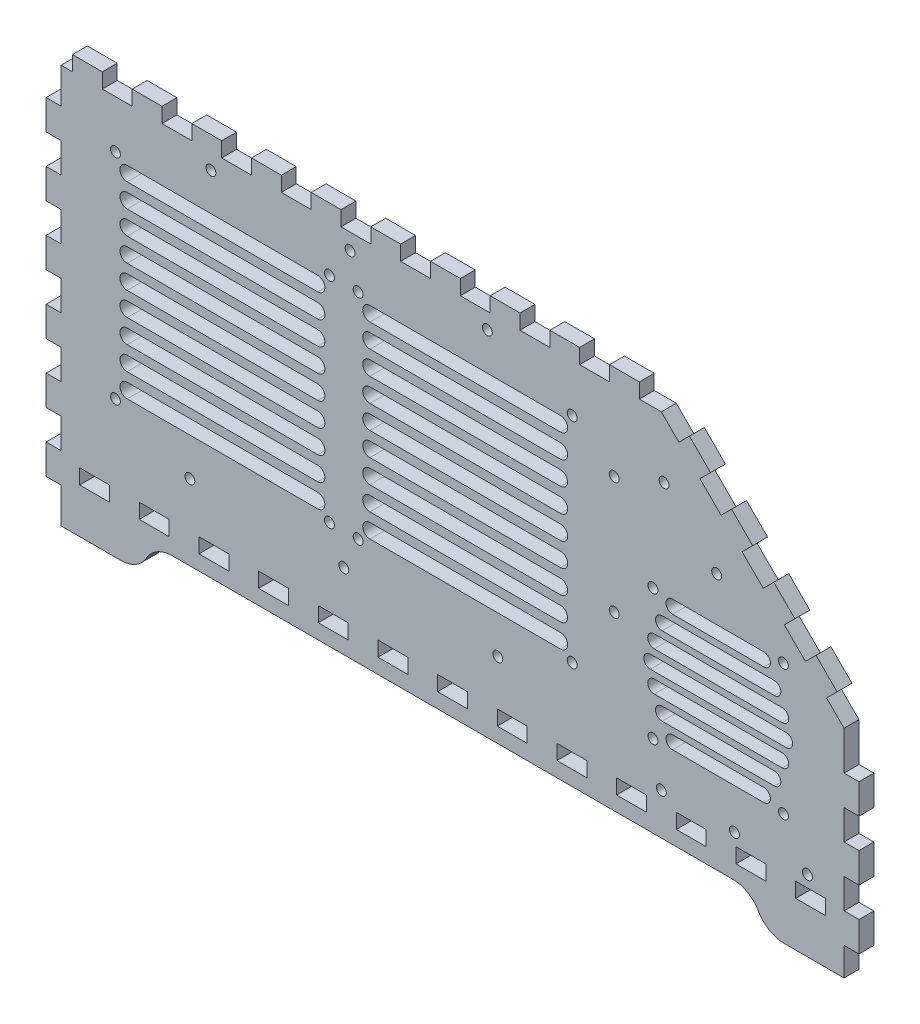
from build123d import *

# Parameters (mm, degrees)
BOSS_EXTRUDE1_DEPTH   = 5.715
CUT_EXTRUDE1_DEPTH    = 6.715
F_6_CLEARANCE_HOLE2_D = 3.7973
CUT_EXTRUDE2_DEPTH    = 10
F_6_CLEARANCE_HOLE1_D = 3.7973
F_6_CLEARANCE_HOLE3_D = 3.7973


with BuildPart() as part:
    # Model → Boss-Extrude1 (new body)
    with BuildSketch(Plane.XY):
        Polygon((16.1148, 22.8575), (38.9749, 22.8575), (39.3485, 22.8575), (40.4689, 22.9567), (41.9322, 23.2475), (43.3447, 23.7271), (44.366, 24.2025), (44.6899, 24.3885), (44.8511, 24.4822), (45.3263, 24.7854), (45.9341, 25.2222), (46.5116, 25.6963), (47.056, 26.2062), (47.5657, 26.7505), (48.0399, 27.3279), (48.4766, 27.9356), (48.7796, 28.411), (48.8735, 28.5722), (48.9673, 28.7348), (49.2689, 29.2103), (49.7057, 29.818), (50.1798, 30.3954), (50.6899, 30.9397), (51.2339, 31.4496), (51.8114, 31.9236), (52.4192, 32.3605), (52.8948, 32.6622), (53.0571, 32.756), (53.3799, 32.9434), (54.4008, 33.4188), (55.8133, 33.8983), (57.2766, 34.1891), (58.3971, 34.287), (58.7721, 34.287), (273.458, 34.287), (273.831, 34.287), (274.952, 34.1891), (276.415, 33.8983), (277.828, 33.4188), (278.849, 32.9434), (279.172, 32.756), (279.334, 32.6636), (279.809, 32.3605), (280.417, 31.9236), (280.995, 31.4496), (281.539, 30.9397), (282.049, 30.3954), (282.523, 29.818), (282.96, 29.2103), (283.263, 28.7348), (283.356, 28.5722), (283.449, 28.411), (283.752, 27.9356), (284.189, 27.3279), (284.663, 26.7505), (285.172, 26.2062), (285.717, 25.6963), (286.294, 25.2222), (286.902, 24.7854), (287.377, 24.4822), (287.54, 24.3885), (287.862, 24.2025), (288.884, 23.7271), (290.296, 23.2475), (291.76, 22.9567), (292.88, 22.8575), (293.255, 22.8575), (316.115, 22.8575), (316.115, 33.6917), (321.83, 33.6917), (321.83, 45.1224), (316.115, 45.1224), (316.115, 56.552), (321.83, 56.552), (321.83, 67.9813), (316.115, 67.9813), (316.115, 79.412), (321.83, 79.412), (321.83, 90.8417), (316.115, 90.8417), (316.115, 101.677), (316.115, 105.718), (309.403, 112.43), (313.444, 116.47), (305.362, 124.553), (301.321, 120.512), (293.238, 128.595), (297.28, 132.635), (289.198, 140.717), (285.156, 136.677), (277.074, 144.759), (281.114, 148.801), (273.032, 156.881), (268.992, 152.841), (260.91, 160.923), (264.951, 164.963), (256.869, 173.046), (252.827, 169.005), (246.115, 175.718), (242.074, 175.718), (237.68, 175.718), (237.68, 181.433), (226.249, 181.433), (226.249, 175.718), (214.82, 175.718), (214.82, 181.433), (203.389, 181.433), (203.389, 175.718), (191.959, 175.718), (191.959, 181.433), (180.53, 181.433), (180.53, 175.718), (169.099, 175.718), (169.099, 181.433), (157.67, 181.433), (157.67, 175.718), (146.239, 175.718), (146.239, 181.433), (134.809, 181.433), (134.809, 175.718), (123.38, 175.718), (123.38, 181.433), (111.949, 181.433), (111.949, 175.718), (100.52, 175.718), (100.52, 181.433), (89.0887, 181.433), (89.0887, 175.718), (77.6594, 175.718), (77.6594, 181.433), (66.2298, 181.433), (66.2298, 175.718), (54.7991, 175.718), (54.7991, 181.433), (43.3698, 181.433), (43.3698, 175.718), (31.9388, 175.718), (31.9388, 181.433), (20.5093, 181.433), (20.5093, 175.718), (16.1148, 175.718), (16.1148, 162.153), (10.4001, 162.153), (10.4001, 150.723), (16.1148, 150.723), (16.1148, 139.292), (10.4001, 139.292), (10.4001, 127.863), (16.1148, 127.863), (16.1148, 116.433), (10.4001, 116.433), (10.4001, 105.003), (16.1148, 105.003), (16.1148, 93.5729), (10.4001, 93.5729), (10.4001, 82.1422), (16.1148, 82.1422), (16.1148, 70.7125), (10.4001, 70.7125), (10.4001, 59.2832), (16.1148, 59.2832), (16.1148, 47.8525), (10.4001, 47.8525), (10.4001, 36.4229), (16.1148, 36.4229), align=None)
        Polygon((28.9553, 40.0032), (23.2406, 40.0032), (23.2406, 45.7179), (34.67, 45.7179), (34.67, 40.0032), align=None, mode=Mode.SUBTRACT)
        Polygon((51.8156, 40.0032), (46.0996, 40.0032), (46.0996, 45.7179), (57.5303, 45.7179), (57.5303, 40.0032), align=None, mode=Mode.SUBTRACT)
        Polygon((74.6746, 40.0032), (68.9599, 40.0032), (68.9599, 45.7179), (80.3906, 45.7179), (80.3906, 40.0032), align=None, mode=Mode.SUBTRACT)
        Polygon((97.5349, 40.0032), (91.8199, 40.0032), (91.8199, 45.7179), (103.25, 45.7179), (103.25, 40.0032), align=None, mode=Mode.SUBTRACT)
        Polygon((120.395, 40.0032), (114.68, 40.0032), (114.68, 45.7179), (126.11, 45.7179), (126.11, 40.0032), align=None, mode=Mode.SUBTRACT)
        Polygon((143.255, 40.0032), (137.541, 40.0032), (137.541, 45.7179), (148.97, 45.7179), (148.97, 40.0032), align=None, mode=Mode.SUBTRACT)
        Polygon((166.116, 40.0032), (160.4, 40.0032), (160.4, 45.7179), (171.83, 45.7179), (171.83, 40.0032), align=None, mode=Mode.SUBTRACT)
        Polygon((188.975, 40.0032), (183.26, 40.0032), (183.26, 45.7179), (194.691, 45.7179), (194.691, 40.0032), align=None, mode=Mode.SUBTRACT)
        Polygon((211.835, 40.0032), (206.12, 40.0032), (206.12, 45.7179), (217.55, 45.7179), (217.55, 40.0032), align=None, mode=Mode.SUBTRACT)
        Polygon((234.695, 40.0032), (228.98, 40.0032), (228.98, 45.7179), (240.41, 45.7179), (240.41, 40.0032), align=None, mode=Mode.SUBTRACT)
        Polygon((257.555, 40.0032), (251.841, 40.0032), (251.841, 45.7179), (263.27, 45.7179), (263.27, 40.0032), align=None, mode=Mode.SUBTRACT)
        Polygon((280.416, 40.0032), (274.7, 40.0032), (274.7, 45.7179), (286.13, 45.7179), (286.13, 40.0032), align=None, mode=Mode.SUBTRACT)
        Polygon((303.275, 40.0032), (297.56, 40.0032), (297.56, 45.7179), (308.991, 45.7179), (308.991, 40.0032), align=None, mode=Mode.SUBTRACT)
    extrude(amount=BOSS_EXTRUDE1_DEPTH)

    # Sketch1 → Cut-Extrude1 (cut, through all)
    with BuildSketch(Plane(origin=(0, 0, 0), x_dir=(-1, 0, 0), z_dir=(0, 0, -1))):
        with BuildLine():
            Line((-285.3976, 115.7127), (-250.3976, 115.7127))
            ThreePointArc((-250.3976, 115.7127), (-247.8976, 113.2127), (-250.3976, 110.7127))
            Line((-250.3976, 110.7127), (-285.3976, 110.7127))
            ThreePointArc((-285.3976, 110.7127), (-287.8976, 113.2127), (-285.3976, 115.7127))
        make_face()
        with BuildLine():
            Line((-289.3976, 103.2127), (-246.3976, 103.2127))
            ThreePointArc((-246.3976, 103.2127), (-243.8976, 105.7127), (-246.3976, 108.2127))
            Line((-246.3976, 108.2127), (-289.3976, 108.2127))
            ThreePointArc((-289.3976, 108.2127), (-291.8976, 105.7127), (-289.3976, 103.2127))
        make_face()
        with BuildLine():
            Line((-292.3976, 95.7127), (-243.3976, 95.7127))
            ThreePointArc((-243.3976, 95.7127), (-240.8976, 98.2127), (-243.3976, 100.7127))
            Line((-243.3976, 100.7127), (-292.3976, 100.7127))
            ThreePointArc((-292.3976, 100.7127), (-294.8976, 98.2127), (-292.3976, 95.7127))
        make_face()
        with BuildLine():
            Line((-293.8976, 88.2127), (-241.8976, 88.2127))
            ThreePointArc((-241.8976, 88.2127), (-239.3976, 90.7127), (-241.8976, 93.2127))
            Line((-241.8976, 93.2127), (-293.8976, 93.2127))
            ThreePointArc((-293.8976, 93.2127), (-296.3976, 90.7127), (-293.8976, 88.2127))
        make_face()
        with BuildLine():
            Line((-292.3976, 80.7127), (-243.3976, 80.7127))
            ThreePointArc((-243.3976, 80.7127), (-240.8976, 83.2127), (-243.3976, 85.7127))
            Line((-243.3976, 85.7127), (-292.3976, 85.7127))
            ThreePointArc((-292.3976, 85.7127), (-294.8976, 83.2127), (-292.3976, 80.7127))
        make_face()
        with BuildLine():
            Line((-289.3976, 73.2127), (-246.3976, 73.2127))
            ThreePointArc((-246.3976, 73.2127), (-243.8976, 75.7127), (-246.3976, 78.2127))
            Line((-246.3976, 78.2127), (-289.3976, 78.2127))
            ThreePointArc((-289.3976, 78.2127), (-291.8976, 75.7127), (-289.3976, 73.2127))
        make_face()
        with BuildLine():
            Line((-285.3976, 65.7127), (-250.3976, 65.7127))
            ThreePointArc((-250.3976, 65.7127), (-247.8976, 68.2127), (-250.3976, 70.7127))
            Line((-250.3976, 70.7127), (-285.3976, 70.7127))
            ThreePointArc((-285.3976, 70.7127), (-287.8976, 68.2127), (-285.3976, 65.7127))
        make_face()
    extrude(amount=-CUT_EXTRUDE1_DEPTH, mode=Mode.SUBTRACT)

    # #6 Clearance Hole2 (through all)
    with Locations(Plane(origin=(0, 0, 0), x_dir=(-1, 0, 0), z_dir=(0, 0, -1))):
        with Locations((-292.8976, 115.7127), (-242.8976, 115.7127), (-292.8976, 65.7127), (-242.8976, 65.7127)):
            Hole(F_6_CLEARANCE_HOLE2_D / 2)

    # Sketch4 → Cut-Extrude2 (cut)
    with BuildSketch(Plane(origin=(0, 0, 0), x_dir=(-1, 0, 0), z_dir=(0, 0, -1))):
        with BuildLine():
            Line((-207.45635, 155.1825), (-134.45635, 155.1825))
            ThreePointArc((-134.45635, 155.1825), (-131.70635, 152.4325), (-134.45635, 149.6825))
            Line((-134.45635, 149.6825), (-207.45635, 149.6825))
            ThreePointArc((-207.45635, 149.6825), (-210.20635, 152.4325), (-207.45635, 155.1825))
        make_face()
        with BuildLine():
            Line((-207.45635, 140.6825), (-134.45635, 140.6825))
            ThreePointArc((-134.45635, 140.6825), (-131.70635, 143.4325), (-134.45635, 146.1825))
            Line((-134.45635, 146.1825), (-207.45635, 146.1825))
            ThreePointArc((-207.45635, 146.1825), (-210.20635, 143.4325), (-207.45635, 140.6825))
        make_face()
        with BuildLine():
            Line((-207.45635, 131.6825), (-134.45635, 131.6825))
            ThreePointArc((-134.45635, 131.6825), (-131.70635, 134.4325), (-134.45635, 137.1825))
            Line((-134.45635, 137.1825), (-207.45635, 137.1825))
            ThreePointArc((-207.45635, 137.1825), (-210.20635, 134.4325), (-207.45635, 131.6825))
        make_face()
        with BuildLine():
            Line((-207.45635, 122.6825), (-134.45635, 122.6825))
            ThreePointArc((-134.45635, 122.6825), (-131.70635, 125.4325), (-134.45635, 128.1825))
            Line((-134.45635, 128.1825), (-207.45635, 128.1825))
            ThreePointArc((-207.45635, 128.1825), (-210.20635, 125.4325), (-207.45635, 122.6825))
        make_face()
        with BuildLine():
            Line((-207.45635, 113.6825), (-134.45635, 113.6825))
            ThreePointArc((-134.45635, 113.6825), (-131.70635, 116.4325), (-134.45635, 119.1825))
            Line((-134.45635, 119.1825), (-207.45635, 119.1825))
            ThreePointArc((-207.45635, 119.1825), (-210.20635, 116.4325), (-207.45635, 113.6825))
        make_face()
        with BuildLine():
            Line((-207.45635, 104.6825), (-134.45635, 104.6825))
            ThreePointArc((-134.45635, 104.6825), (-131.70635, 107.4325), (-134.45635, 110.1825))
            Line((-134.45635, 110.1825), (-207.45635, 110.1825))
            ThreePointArc((-207.45635, 110.1825), (-210.20635, 107.4325), (-207.45635, 104.6825))
        make_face()
        with BuildLine():
            Line((-207.45635, 95.6825), (-134.45635, 95.6825))
            ThreePointArc((-134.45635, 95.6825), (-131.70635, 98.4325), (-134.45635, 101.1825))
            Line((-134.45635, 101.1825), (-207.45635, 101.1825))
            ThreePointArc((-207.45635, 101.1825), (-210.20635, 98.4325), (-207.45635, 95.6825))
        make_face()
        with BuildLine():
            Line((-207.45635, 86.6825), (-134.45635, 86.6825))
            ThreePointArc((-134.45635, 86.6825), (-131.70635, 89.4325), (-134.45635, 92.1825))
            Line((-134.45635, 92.1825), (-207.45635, 92.1825))
            ThreePointArc((-207.45635, 92.1825), (-210.20635, 89.4325), (-207.45635, 86.6825))
        make_face()
        with BuildLine():
            Line((-207.45635, 77.6825), (-134.45635, 77.6825))
            ThreePointArc((-134.45635, 77.6825), (-131.70635, 80.4325), (-134.45635, 83.1825))
            Line((-134.45635, 83.1825), (-207.45635, 83.1825))
            ThreePointArc((-207.45635, 83.1825), (-210.20635, 80.4325), (-207.45635, 77.6825))
        make_face()
        with BuildLine():
            Line((-41.45635, 83.1825), (-114.45635, 83.1825))
            ThreePointArc((-114.45635, 83.1825), (-117.20635, 80.4325), (-114.45635, 77.6825))
            Line((-114.45635, 77.6825), (-41.45635, 77.6825))
            ThreePointArc((-41.45635, 77.6825), (-38.70635, 80.4325), (-41.45635, 83.1825))
        make_face()
        with BuildLine():
            Line((-41.45635, 92.1825), (-114.45635, 92.1825))
            ThreePointArc((-114.45635, 92.1825), (-117.20635, 89.4325), (-114.45635, 86.6825))
            Line((-114.45635, 86.6825), (-41.45635, 86.6825))
            ThreePointArc((-41.45635, 86.6825), (-38.70635, 89.4325), (-41.45635, 92.1825))
        make_face()
        with BuildLine():
            Line((-41.45635, 101.1825), (-114.45635, 101.1825))
            ThreePointArc((-114.45635, 101.1825), (-117.20635, 98.4325), (-114.45635, 95.6825))
            Line((-114.45635, 95.6825), (-41.45635, 95.6825))
            ThreePointArc((-41.45635, 95.6825), (-38.70635, 98.4325), (-41.45635, 101.1825))
        make_face()
        with BuildLine():
            Line((-41.45635, 110.1825), (-114.45635, 110.1825))
            ThreePointArc((-114.45635, 110.1825), (-117.20635, 107.4325), (-114.45635, 104.6825))
            Line((-114.45635, 104.6825), (-41.45635, 104.6825))
            ThreePointArc((-41.45635, 104.6825), (-38.70635, 107.4325), (-41.45635, 110.1825))
        make_face()
        with BuildLine():
            Line((-41.45635, 119.1825), (-114.45635, 119.1825))
            ThreePointArc((-114.45635, 119.1825), (-117.20635, 116.4325), (-114.45635, 113.6825))
            Line((-114.45635, 113.6825), (-41.45635, 113.6825))
            ThreePointArc((-41.45635, 113.6825), (-38.70635, 116.4325), (-41.45635, 119.1825))
        make_face()
        with BuildLine():
            Line((-41.45635, 128.1825), (-114.45635, 128.1825))
            ThreePointArc((-114.45635, 128.1825), (-117.20635, 125.4325), (-114.45635, 122.6825))
            Line((-114.45635, 122.6825), (-41.45635, 122.6825))
            ThreePointArc((-41.45635, 122.6825), (-38.70635, 125.4325), (-41.45635, 128.1825))
        make_face()
        with BuildLine():
            Line((-41.45635, 137.1825), (-114.45635, 137.1825))
            ThreePointArc((-114.45635, 137.1825), (-117.20635, 134.4325), (-114.45635, 131.6825))
            Line((-114.45635, 131.6825), (-41.45635, 131.6825))
            ThreePointArc((-41.45635, 131.6825), (-38.70635, 134.4325), (-41.45635, 137.1825))
        make_face()
        with BuildLine():
            Line((-41.45635, 146.1825), (-114.45635, 146.1825))
            ThreePointArc((-114.45635, 146.1825), (-117.20635, 143.4325), (-114.45635, 140.6825))
            Line((-114.45635, 140.6825), (-41.45635, 140.6825))
            ThreePointArc((-41.45635, 140.6825), (-38.70635, 143.4325), (-41.45635, 146.1825))
        make_face()
        with BuildLine():
            Line((-41.45635, 155.1825), (-114.45635, 155.1825))
            ThreePointArc((-114.45635, 155.1825), (-117.20635, 152.4325), (-114.45635, 149.6825))
            Line((-114.45635, 149.6825), (-41.45635, 149.6825))
            ThreePointArc((-41.45635, 149.6825), (-38.70635, 152.4325), (-41.45635, 155.1825))
        make_face()
    extrude(amount=-CUT_EXTRUDE2_DEPTH, mode=Mode.SUBTRACT)

    # #6 Clearance Hole1 (through all)
    with Locations(Plane(origin=(0, 0, 0), x_dir=(-1, 0, 0), z_dir=(0, 0, -1))):
        with Locations((-211.95635, 157.4325), (-129.95635, 157.4325), (-118.95635, 157.4325), (-36.95635, 157.4325), (-36.95635, 75.4325), (-118.95635, 75.4325), (-129.95635, 75.4325), (-211.95635, 75.4325)):
            Hole(F_6_CLEARANCE_HOLE1_D / 2)

    # #6 Clearance Hole3 (through all)
    with Locations(Plane.XY.offset(5.715)):
        with Locations((73.531766667, 169.575), (126.8651, 169.575), (179.448433333, 169.575), (65.45635, 63.2127), (183.45635, 63.2127), (124.45635, 63.2127), (228.0476, 145.2151), (228.0476, 100.2151), (246.1141, 50.2127), (274.1141, 50.2127), (302.1141, 50.2127), (267.297987771, 132.605302012), (247.145444507, 152.757845276)):
            Hole(F_6_CLEARANCE_HOLE3_D / 2)


solid = part.part
